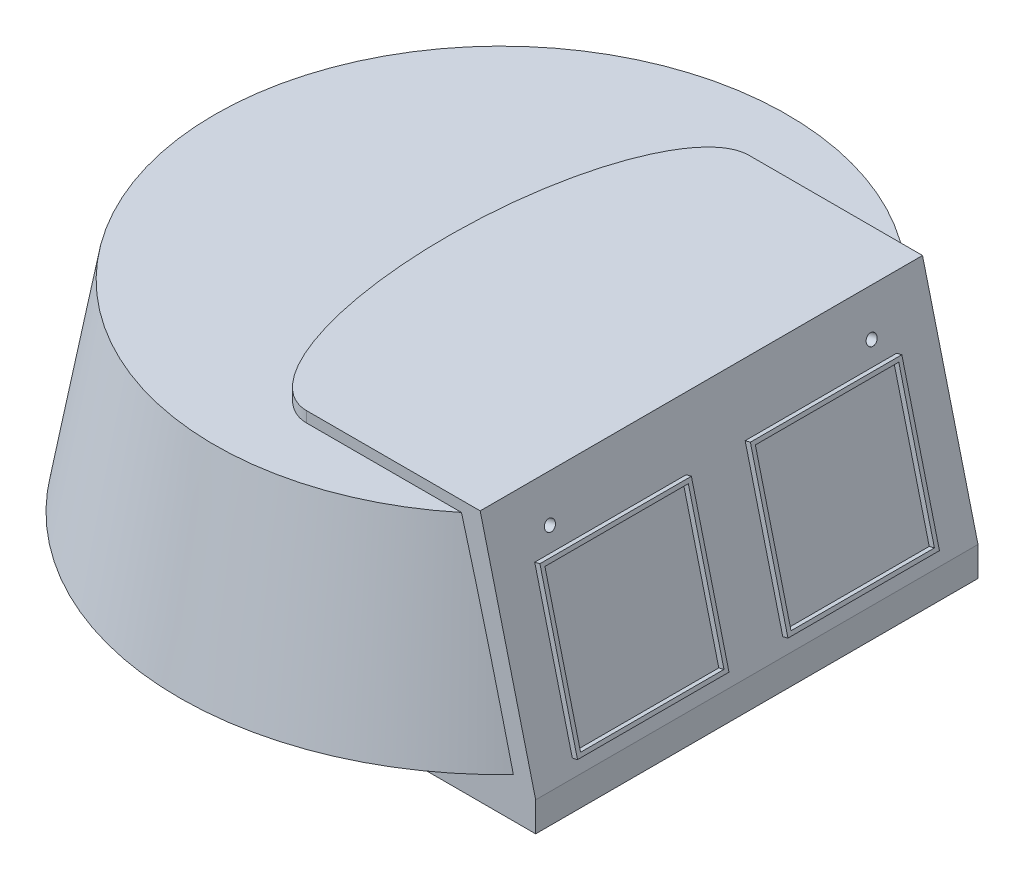
from build123d import *

# Parameters (mm, degrees)
BOSS_EXTRUDE6_DEPTH     = 165
CUT_EXTRUDE3_DEPTH      = 381.566986876
CUT_EXTRUDE3_DEPTH_BACK = 381.566986876
SHELL1_T                = -10
SKETCH8_W               = 113
SKETCH8_H               = 116
SKETCH8_W_2             = 107
SKETCH8_H_2             = 110
BOSS_EXTRUDE5_DEPTH     = 4
SKETCH4_RX              = 165
SKETCH4_RY              = 60
BOSS_EXTRUDE7_DEPTH     = 8
SKETCH9_R               = 4
CUT_EXTRUDE4_DEPTH      = 10
SCALE1_SCALE            = 0.5


with BuildPart() as part:
    # Sketch1 → Revolve1 (revolve)
    with BuildSketch(Plane.XY, mode=Mode.PRIVATE) as revolve1_sk:
        Polygon((240, 0), (213.550952894, 150), (0, 150), (0, 0), (0, -30), (180, -30), (193.356860559, 0), align=None)
    revolve(revolve1_sk.sketch.rotate(Axis((0, 150, 0), (0, -1, 0)), 180), axis=Axis((0, 150, 0), (0, -1, 0)))

    # Sketch2 → Boss-Extrude6 (add, symmetric)
    with BuildSketch(Plane.XY):
        Polygon((20, -30), (144.519146375, -30), (249.534028741, -30), (249.534028741, -8), (220.263749943, 158), (20, 158), align=None)
    extrude(amount=BOSS_EXTRUDE6_DEPTH, both=True)

    # Sketch5 → Revolve3 (revolve)
    with BuildSketch(Plane.XY, mode=Mode.PRIVATE) as revolve3_sk:
        Polygon((0, -30), (0, -60), (90, -60), (105, -30), align=None)
    revolve(revolve3_sk.sketch.rotate(Axis((0, -30, 0), (0, -1, 0)), 180), axis=Axis((0, -30, 0), (0, -1, 0)))

    # Sketch7 → Cut-Extrude3 (cut, two sides)
    with BuildSketch(Plane.XY) as cut_extrude3_sk:
        Polygon((149.534028741, 158), (190.922477213, -8), (190.922477213, -30), (249.534028741, -30), (249.534028741, 158), align=None)
    extrude(amount=CUT_EXTRUDE3_DEPTH, mode=Mode.SUBTRACT)
    extrude(cut_extrude3_sk.sketch, amount=-CUT_EXTRUDE3_DEPTH_BACK, mode=Mode.SUBTRACT)

    # Shell1
    shell1_openings = [part.faces().sort_by_distance(p)[0] for p in [
        (0, -60, 0),
    ]]
    offset(amount=SHELL1_T, openings=shell1_openings, kind=Kind.INTERSECTION)

    # Sketch8 → Boss-Extrude5 (add)
    with BuildSketch(Plane(origin=(177.870623194, 44.348127245, 0), x_dir=(0, 0, -1), z_dir=(0.9702957262759971, 0.24192189559966487, 0))):
        with Locations((-78.5, 15)):
            Rectangle(SKETCH8_W, SKETCH8_H)
        with Locations((-78.5, 15)):
            Rectangle(SKETCH8_W_2, SKETCH8_H_2, mode=Mode.SUBTRACT)
        with Locations((78.5, 15)):
            Rectangle(SKETCH8_W, SKETCH8_H)
        with Locations((78.5, 15)):
            Rectangle(SKETCH8_W_2, SKETCH8_H_2, mode=Mode.SUBTRACT)
    extrude(amount=BOSS_EXTRUDE5_DEPTH)

    # Sketch4 → Boss-Extrude7 (add)
    with BuildSketch(Plane(origin=(0, 150, 0), x_dir=(1, 0, 0), z_dir=(0, 1, 0))):
        with Locations(Location((20, 0), (0, 0, 90))):
            Ellipse(SKETCH4_RX, SKETCH4_RY)
    extrude(amount=BOSS_EXTRUDE7_DEPTH)

    # Sketch9 → Cut-Extrude4 (cut)
    with BuildSketch(Plane(origin=(177.870623194, 44.348127245, 0), x_dir=(0, 0, -1), z_dir=(0.9702957262759971, 0.24192189559966487, 0))):
        with Locations(Location((-120, 88, 0), (0, 0, 90))):
            Circle(SKETCH9_R)
    cut_extrude4 = extrude(amount=-CUT_EXTRUDE4_DEPTH, mode=Mode.SUBTRACT)

    # Mirror1: Cut-Extrude4 across plane
    add(cut_extrude4.mirror(Plane.XY), mode=Mode.SUBTRACT)


with BuildPart() as part_1:
    # Scale1: scaled about (0, 0, 0)
    add(part.part.scale(SCALE1_SCALE))


solid = part_1.part
